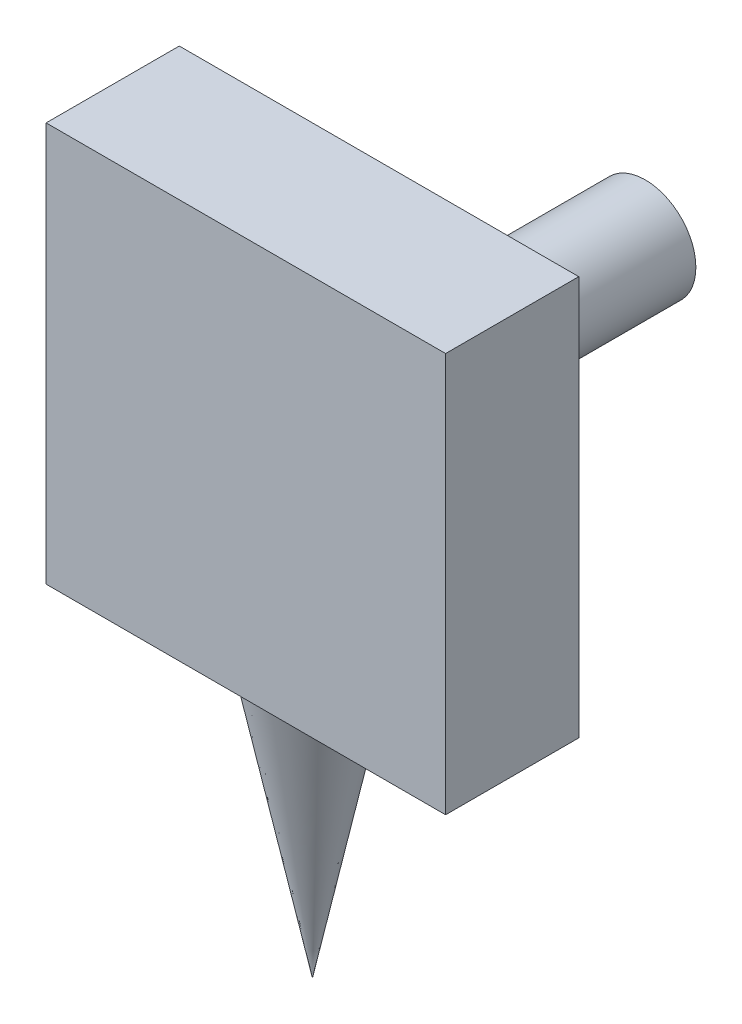
from build123d import *

# Parameters (mm, degrees)
SKETCH1_R           = 3.795
BOSS_EXTRUDE1_DEPTH = 20
SKETCH2_W           = 30
SKETCH2_H           = 30
BOSS_EXTRUDE2_DEPTH = 10


with BuildPart() as part:
    # Sketch1 → Boss-Extrude1 (new body)
    with BuildSketch(Plane.XY):
        with Locations((126.972995011, 125.730606971)):
            Circle(SKETCH1_R)
    extrude(amount=-BOSS_EXTRUDE1_DEPTH)

    # Sketch2 → Boss-Extrude2 (add)
    with BuildSketch(Plane.XY):
        with Locations((126.972995011, 125.730606971)):
            Rectangle(SKETCH2_W, SKETCH2_H)
    extrude(amount=BOSS_EXTRUDE2_DEPTH)

    # Sketch3 → Revolve1 (revolve)
    with BuildSketch(Plane(origin=(126.972995011, 0, 0), x_dir=(0, 0, -1), z_dir=(1, 0, 0))):
        Polygon((-0.758524561, 110.730606971), (-5, 90.117115807), (-5, 110.730606971), align=None)
    revolve(axis=Axis((126.972995011, 90.117115807, 5), (0, 1, 0)))


solid = part.part
